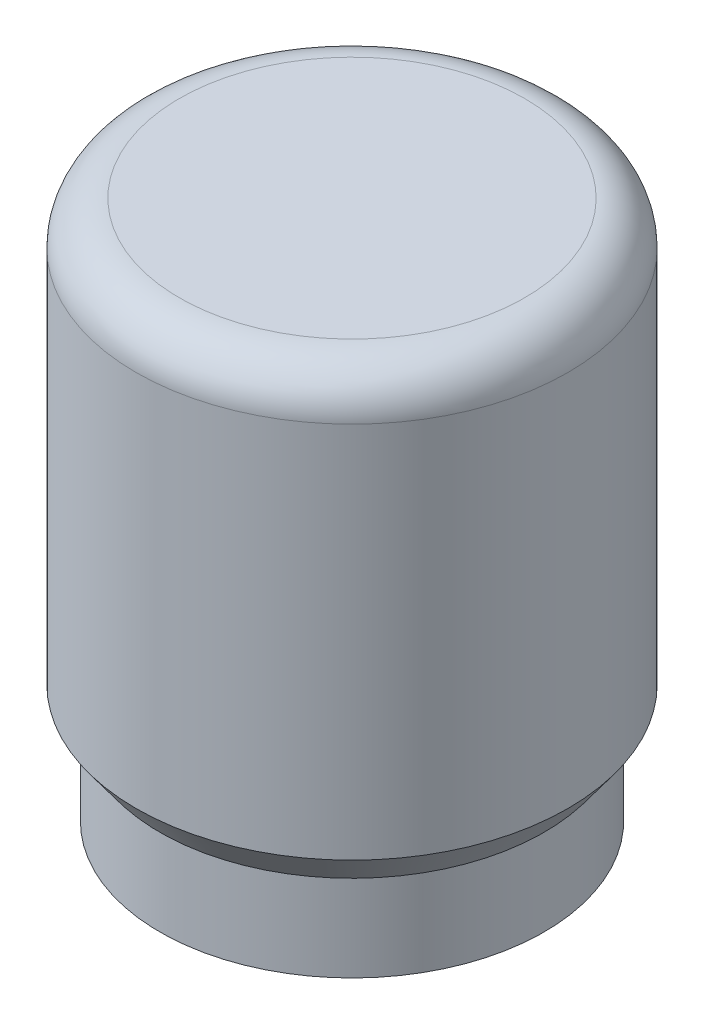
from build123d import *

# Parameters (mm, degrees)
SKETCH2_R          = 1.7272
CUT_EXTRUDE1_DEPTH = 7.35


with BuildPart() as part:
    # Sketch1 → Revolve1 (revolve)
    with BuildSketch(Plane.XY, mode=Mode.PRIVATE) as revolve1_sk:
        with BuildLine():
            Line((3, 3.9878), (3, 12.954))
            Line((3, 12.954), (0, 14.686050808))
            Line((0, 14.686050808), (0, 15.875))
            Line((0, 15.875), (5.08, 15.875))
            ThreePointArc((5.08, 15.875), (5.978025612, 15.503025612), (6.35, 14.605))
            Line((6.35, 14.605), (6.35, 3.495842105))
            Line((6.35, 3.495842105), (5.6515, 2.54))
            Line((5.6515, 2.54), (5.6515, 0))
            Line((5.6515, 0), (4.7625, 0))
            Line((4.7625, 0), (4.7625, 3.9878))
            Line((4.7625, 3.9878), (3, 3.9878))
        make_face()
    revolve(revolve1_sk.sketch.rotate(Axis((0, 0, 0), (0, 1, 0)), 90), axis=Axis((0, 0, 0), (0, 1, 0)))  # turned: the seam where the file's is

    # Sketch2 → Cut-Extrude1 (cut, through all)
    with BuildSketch(Plane.XY):
        with Locations(Location((0, 7.239, 0), (0, 0, 90))):  # turned: the seam where the file's is
            Circle(SKETCH2_R)
    extrude(amount=-CUT_EXTRUDE1_DEPTH, mode=Mode.SUBTRACT)


solid = part.part
